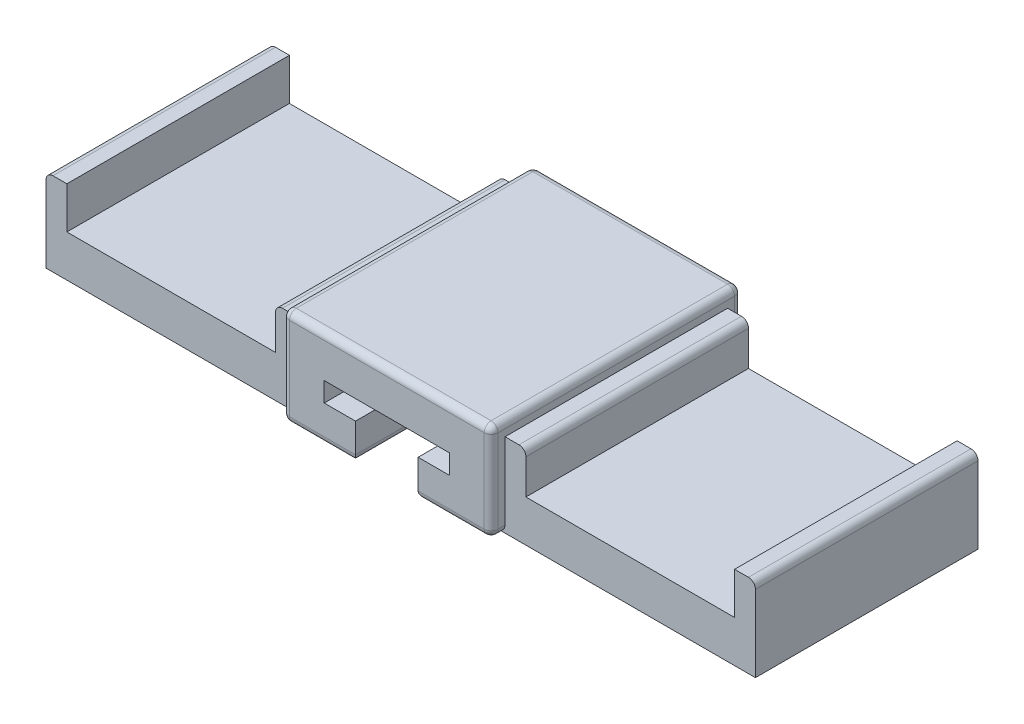
from build123d import *

# Parameters (mm, degrees)
SKETCH1_W           = 15
SKETCH1_H           = 18
BOSS_EXTRUDE1_DEPTH = 7
CUT_EXTRUDE1_DEPTH  = 16.2
SKETCH9_W           = 16
SKETCH9_H           = 6
BOSS_EXTRUDE2_DEPTH = 18
SKETCH13_W          = 16
SKETCH13_H          = 6
BOSS_EXTRUDE3_DEPTH = 18
SKETCH14_W          = 15
SKETCH14_H          = 3
CUT_EXTRUDE5_DEPTH  = 32.55
FILLET1_R           = 0.5


with BuildPart() as part:
    # Sketch1 → Boss-Extrude1 (new body)
    with BuildSketch(Plane(origin=(0, 0, 0), x_dir=(1, 0, 0), z_dir=(0, 1, 0))):
        Rectangle(SKETCH1_W, SKETCH1_H)
    extrude(amount=BOSS_EXTRUDE1_DEPTH)

    # Sketch2 → Cut-Extrude1 (cut)
    with BuildSketch(Plane.XY.offset(9)):
        Polygon((-2.25, 2.6), (-2.25, 0), (2.25, 0), (2.25, 2.6), (4.5, 2.6), (4.5, 4), (-4.5, 4), (-4.5, 2.6), align=None)
    extrude(amount=-CUT_EXTRUDE1_DEPTH, mode=Mode.SUBTRACT)

    # Sketch9 → Boss-Extrude2 (add)
    with BuildSketch(Plane.ZY.offset(7.5)):
        with Locations((0, 3)):
            Rectangle(SKETCH9_W, SKETCH9_H)
    extrude(amount=BOSS_EXTRUDE2_DEPTH)

    # Sketch13 → Boss-Extrude3 (add)
    with BuildSketch(Plane(origin=(7.5, 0, 0), x_dir=(0, 0, -1), z_dir=(1, 0, 0))):
        with Locations((0, 3)):
            Rectangle(SKETCH13_W, SKETCH13_H)
    extrude(amount=BOSS_EXTRUDE3_DEPTH)

    # Sketch14 → Cut-Extrude5 (cut)
    with BuildSketch(Plane.XY.offset(9)):
        with Locations((16.5, 4.5)):
            Rectangle(SKETCH14_W, SKETCH14_H)
        with Locations((-16.5, 4.5)):
            Rectangle(SKETCH14_W, SKETCH14_H)
    extrude(amount=-CUT_EXTRUDE5_DEPTH, mode=Mode.SUBTRACT)

    # Fillet1
    fillet1_edges = [part.edges().sort_by_distance(p)[0] for p in [
        (-7.5, 7, 0),
        (4.875, 0, 9),
        (0, 7, 9),
        (-2.25, 0, 0.9),
        (2.25, 0, 0.9),
        (-7.5, 0, 8.5),
        (-25.5, 6, 0),
        (7.5, 7, 0),
        (-4.875, 0, 9),
        (-7.5, 0, -8.5),
        (0, 0, -9),
        (7.5, 0, -8.5),
        (7.5, 0, 8.5),
        (25.5, 6, 0),
        (7.5, 3.5, 9),
        (-7.5, 3.5, 9),
        (-7.5, 3.5, -9),
        (9, 6, 0),
        (7.5, 3.5, -9),
        (0, 7, -9),
        (-9, 6, 0),
    ]]
    fillet(fillet1_edges, radius=FILLET1_R)


solid = part.part
